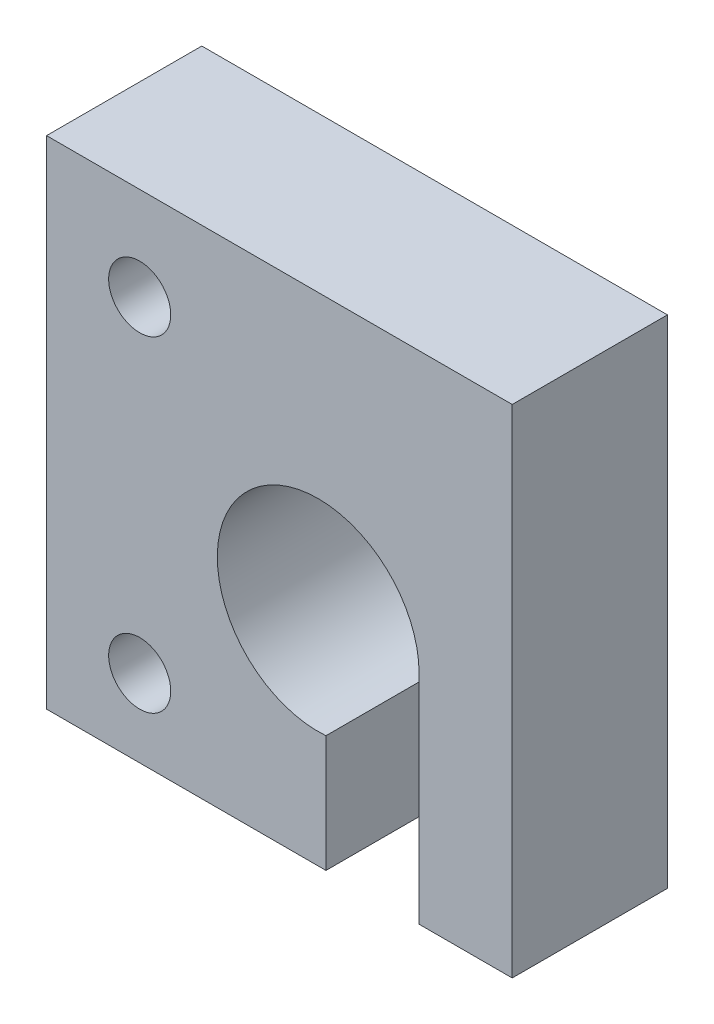
from build123d import *

# Parameters (mm, degrees)
SKETCH_2_R      = 2
EXTRUDE_1_DEPTH = 10


with BuildPart() as part:
    # Эскиз2 → Бобышка-Вытянуть1 (new body)
    with BuildSketch(Plane.XY):
        with BuildLine():
            Line((6.5, 0), (6.5, -14))
            Line((6.5, -14), (12.5, -14))
            Line((12.5, -14), (12.5, 18))
            Line((12.5, 18), (-17.5, 18))
            Line((-17.5, 18), (-17.5, -14))
            Line((-17.5, -14), (0.5, -14))
            Line((0.5, -14), (0.5, -6.480740698))
            ThreePointArc((0.5, -6.480740698), (-4.769696007, 4.415880433), (6.5, 0))
        make_face()
        with Locations((-11.5, 12)):
            Circle(SKETCH_2_R, mode=Mode.SUBTRACT)
        with Locations((-11.5, -9)):
            Circle(SKETCH_2_R, mode=Mode.SUBTRACT)
    extrude(amount=EXTRUDE_1_DEPTH)


solid = part.part
